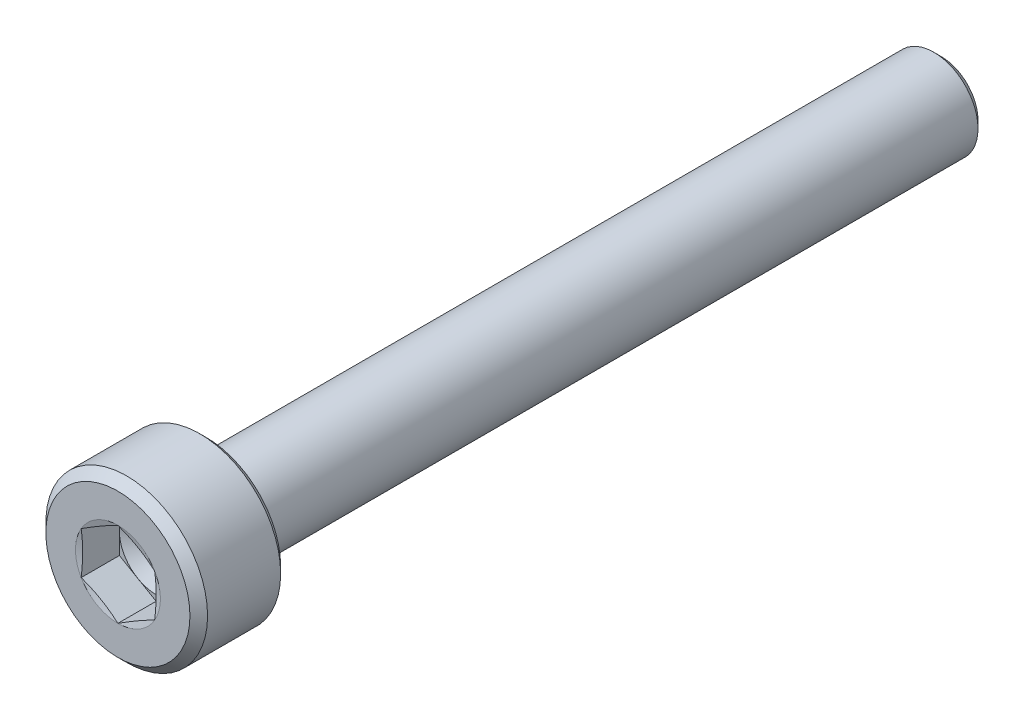
from build123d import *

# Parameters (mm, degrees)
CUT_EXTRUDE1_DEPTH = 1.3


with BuildPart() as part:
    # Sketch1 → Revolve1 (revolve)
    with BuildSketch(Plane(origin=(0, 0, 0), x_dir=(0, 0, -1), z_dir=(1, 0, 0))):
        with BuildLine():
            Line((0, 0), (0, 2.45))
            Line((0, 2.45), (0.3, 2.75))
            Line((0.3, 2.75), (2.785, 2.75))
            Line((2.785, 2.75), (3, 2.535))
            Line((3, 2.535), (3, 1.8))
            ThreePointArc((3, 1.8), (3.015193643, 1.74701055), (3.056157637, 1.710123155))
            Line((3.056157637, 1.710123155), (3.466157637, 1.510123155))
            ThreePointArc((3.466157637, 1.510123155), (3.48750205, 1.50256365), (3.51, 1.5))
            Line((3.51, 1.5), (27.75, 1.5))
            Line((27.75, 1.5), (28, 1.25))
            Line((28, 1.25), (28, 0))
            Line((28, 0), (0, 0))
        make_face()
    revolve(axis=Axis((0, 0, 0), (0, 0, -1)))

    # Sketch2 → Cut-Extrude1 (cut)
    with BuildSketch(Plane.XY):
        Polygon((0, 1.443375673), (-1.25, 0.721687836), (-1.25, -0.721687836), (0, -1.443375673), (1.25, -0.721687836), (1.25, 0.721687836), align=None)
    extrude(amount=-CUT_EXTRUDE1_DEPTH, mode=Mode.SUBTRACT)

    # Sketch3 → Cut-Revolve2 (revolve, cut)
    with BuildSketch(Plane(origin=(0, 0, 0), x_dir=(0, 0, -1), z_dir=(1, 0, 0))):
        Polygon((1.3, 0), (1.3, 1.25), (2.021687836, 0), align=None)
    revolve(axis=Axis((0, 0, -1.3), (0, 0, -1)), mode=Mode.SUBTRACT)

    # Sketch4 → Cut-Revolve3 (revolve, cut)
    with BuildSketch(Plane(origin=(0, 0, 0), x_dir=(0, 0, -1), z_dir=(1, 0, 0))):
        Polygon((0, 1.443375673), (0, 1.25), (0.051814855, 1.25), align=None)
    revolve(axis=Axis((0, 0, 0), (0, 0, -1)), mode=Mode.SUBTRACT)


solid = part.part
